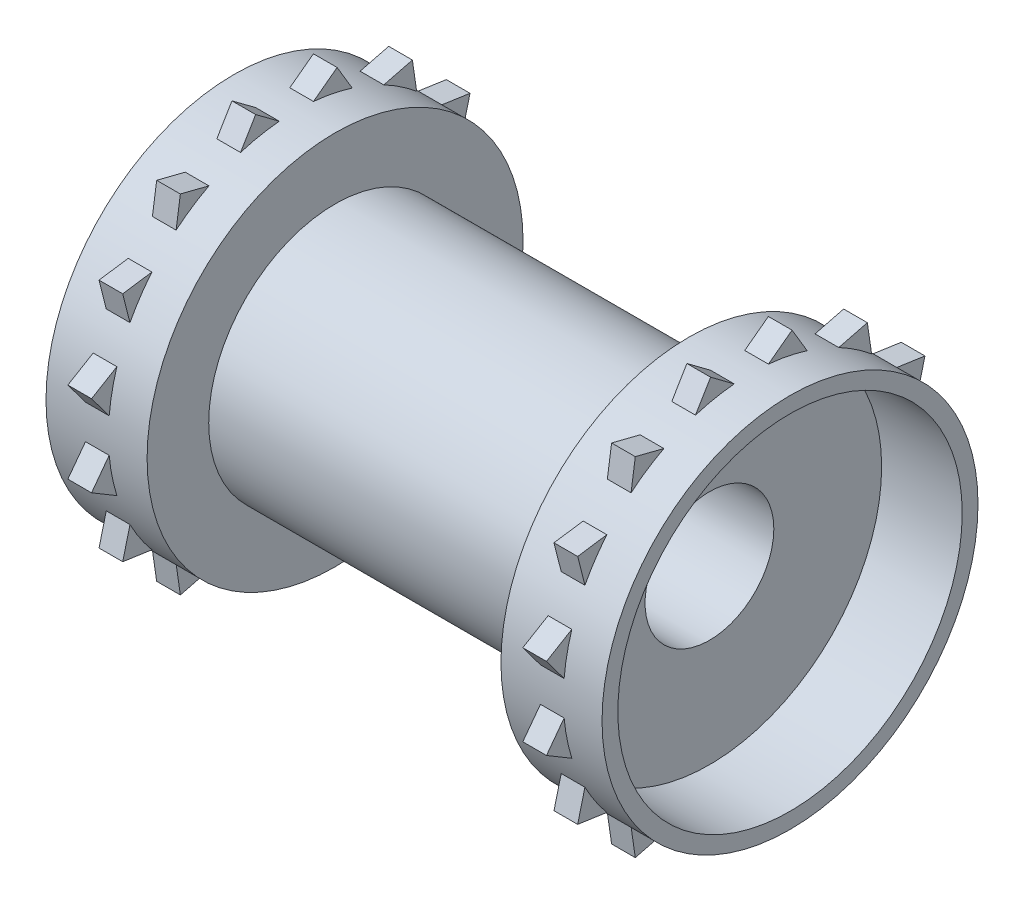
from build123d import *

# Parameters (mm, degrees)
CROQUIS1_R              = 8
CROQUIS1_R_2            = 4.075
SALIENTE_EXTRUIR1_DEPTH = 11.2
CROQUIS3_R              = 11.9
CROQUIS3_R_2            = 4.075
SALIENTE_EXTRUIR2_DEPTH = 1.3
CROQUIS4_R              = 11.9
CROQUIS4_R_2            = 10.9
SALIENTE_EXTRUIR3_DEPTH = 5.1
SALIENTE_EXTRUIR4_DEPTH = 0.75
CROQUIS6_R              = 2.5
CORTAR_EXTRUIR1_DEPTH   = 13.966428038


with BuildPart() as part:
    # Croquis1 → Saliente-Extruir1 (new body, symmetric)
    with BuildSketch(Plane(origin=(0, 0, 0), x_dir=(0, 0, -1), z_dir=(1, 0, 0))):
        Circle(CROQUIS1_R)
        Circle(CROQUIS1_R_2, mode=Mode.SUBTRACT)
    extrude(amount=SALIENTE_EXTRUIR1_DEPTH, both=True)

    # Croquis3 → Saliente-Extruir2 (add)
    with BuildSketch(Plane(origin=(11.2, 0, 0), x_dir=(0, 0, -1), z_dir=(1, 0, 0))):
        Circle(CROQUIS3_R)
        Circle(CROQUIS3_R_2, mode=Mode.SUBTRACT)
    saliente_extruir2 = extrude(amount=SALIENTE_EXTRUIR2_DEPTH)

    # Croquis4 → Saliente-Extruir3 (add)
    with BuildSketch(Plane(origin=(12.5, 0, 0), x_dir=(0, 0, -1), z_dir=(1, 0, 0))):
        Circle(CROQUIS4_R)
        Circle(CROQUIS4_R_2, mode=Mode.SUBTRACT)
    saliente_extruir3 = extrude(amount=SALIENTE_EXTRUIR3_DEPTH)

    # Simetría1: Saliente-Extruir2, Saliente-Extruir3 across plane
    add(saliente_extruir2.mirror(Plane(origin=(0, 0, 0), x_dir=(0, 0, 1), z_dir=(1, 0, 0))))
    add(saliente_extruir3.mirror(Plane(origin=(0, 0, 0), x_dir=(0, 0, 1), z_dir=(1, 0, 0))))

    # Croquis5 → Saliente-Extruir4 (add, symmetric)
    with BuildSketch(Plane(origin=(14.4, 0, 0), x_dir=(0, 0, -1), z_dir=(1, 0, 0))):
        with BuildLine():
            Line((2.579182897, 12.966428038), (3.534712981, 11.362913541))
            ThreePointArc((3.534712981, 11.362913541), (2.321574832, 11.671344837), (1.08274978, 11.850639346))
            Line((1.08274978, 11.850639346), (2.579182897, 12.966428038))
        make_face()
        with BuildLine():
            Line((7.344891477, 10.99240691), (7.614047732, 9.145287155))
            ThreePointArc((7.614047732, 9.145287155), (6.611285773, 9.894488386), (5.535373701, 10.534212737))
            Line((5.535373701, 10.534212737), (7.344891477, 10.99240691))
        make_face()
        with BuildLine():
            Line((10.99240691, 7.344891477), (10.534212737, 5.535373701))
            ThreePointArc((10.534212737, 5.535373701), (9.894488386, 6.611285773), (9.145287155, 7.614047732))
            Line((9.145287155, 7.614047732), (10.99240691, 7.344891477))
        make_face()
        with BuildLine():
            Line((12.966428038, 2.579182897), (11.850639346, 1.08274978))
            ThreePointArc((11.850639346, 1.08274978), (11.671344837, 2.321574832), (11.362913541, 3.534712981))
            Line((11.362913541, 3.534712981), (12.966428038, 2.579182897))
        make_face()
        with BuildLine():
            Line((12.966428038, -2.579182897), (11.362913541, -3.534712981))
            ThreePointArc((11.362913541, -3.534712981), (11.671344837, -2.321574832), (11.850639346, -1.08274978))
            Line((11.850639346, -1.08274978), (12.966428038, -2.579182897))
        make_face()
        with BuildLine():
            Line((10.99240691, -7.344891477), (9.145287155, -7.614047732))
            ThreePointArc((9.145287155, -7.614047732), (9.894488386, -6.611285773), (10.534212737, -5.535373701))
            Line((10.534212737, -5.535373701), (10.99240691, -7.344891477))
        make_face()
        with BuildLine():
            Line((7.344891477, -10.99240691), (5.535373701, -10.534212737))
            ThreePointArc((5.535373701, -10.534212737), (6.611285773, -9.894488386), (7.614047732, -9.145287155))
            Line((7.614047732, -9.145287155), (7.344891477, -10.99240691))
        make_face()
        with BuildLine():
            Line((2.579182897, -12.966428038), (1.08274978, -11.850639346))
            ThreePointArc((1.08274978, -11.850639346), (2.321574832, -11.671344837), (3.534712981, -11.362913541))
            Line((3.534712981, -11.362913541), (2.579182897, -12.966428038))
        make_face()
        with BuildLine():
            Line((-2.579182897, -12.966428038), (-3.534712981, -11.362913541))
            ThreePointArc((-3.534712981, -11.362913541), (-2.321574832, -11.671344837), (-1.08274978, -11.850639346))
            Line((-1.08274978, -11.850639346), (-2.579182897, -12.966428038))
        make_face()
        with BuildLine():
            Line((-7.344891477, -10.99240691), (-7.614047732, -9.145287155))
            ThreePointArc((-7.614047732, -9.145287155), (-6.611285773, -9.894488386), (-5.535373701, -10.534212737))
            Line((-5.535373701, -10.534212737), (-7.344891477, -10.99240691))
        make_face()
        with BuildLine():
            Line((-10.99240691, -7.344891477), (-10.534212737, -5.535373701))
            ThreePointArc((-10.534212737, -5.535373701), (-9.894488386, -6.611285773), (-9.145287155, -7.614047732))
            Line((-9.145287155, -7.614047732), (-10.99240691, -7.344891477))
        make_face()
        with BuildLine():
            Line((-12.966428038, -2.579182897), (-11.850639346, -1.08274978))
            ThreePointArc((-11.850639346, -1.08274978), (-11.671344837, -2.321574832), (-11.362913541, -3.534712981))
            Line((-11.362913541, -3.534712981), (-12.966428038, -2.579182897))
        make_face()
        with BuildLine():
            Line((-12.966428038, 2.579182897), (-11.362913541, 3.534712981))
            ThreePointArc((-11.362913541, 3.534712981), (-11.671344837, 2.321574832), (-11.850639346, 1.08274978))
            Line((-11.850639346, 1.08274978), (-12.966428038, 2.579182897))
        make_face()
        with BuildLine():
            Line((-10.99240691, 7.344891477), (-9.145287155, 7.614047732))
            ThreePointArc((-9.145287155, 7.614047732), (-9.894488386, 6.611285773), (-10.534212737, 5.535373701))
            Line((-10.534212737, 5.535373701), (-10.99240691, 7.344891477))
        make_face()
        with BuildLine():
            Line((-7.344891477, 10.99240691), (-5.535373701, 10.534212737))
            ThreePointArc((-5.535373701, 10.534212737), (-6.611285773, 9.894488386), (-7.614047732, 9.145287155))
            Line((-7.614047732, 9.145287155), (-7.344891477, 10.99240691))
        make_face()
        with BuildLine():
            Line((-2.579182897, 12.966428038), (-1.08274978, 11.850639346))
            ThreePointArc((-1.08274978, 11.850639346), (-2.321574832, 11.671344837), (-3.534712981, 11.362913541))
            Line((-3.534712981, 11.362913541), (-2.579182897, 12.966428038))
        make_face()
    saliente_extruir4 = extrude(amount=SALIENTE_EXTRUIR4_DEPTH, both=True)

    # Simetría2: Saliente-Extruir4 across plane
    add(saliente_extruir4.mirror(Plane(origin=(0, 0, 0), x_dir=(0, 0, 1), z_dir=(1, 0, 0))))

    # Croquis6 → Cortar-Extruir1 (cut, through all)
    with BuildSketch(Plane.XY):
        Circle(CROQUIS6_R)
    extrude(amount=-CORTAR_EXTRUIR1_DEPTH, mode=Mode.SUBTRACT)


solid = part.part
